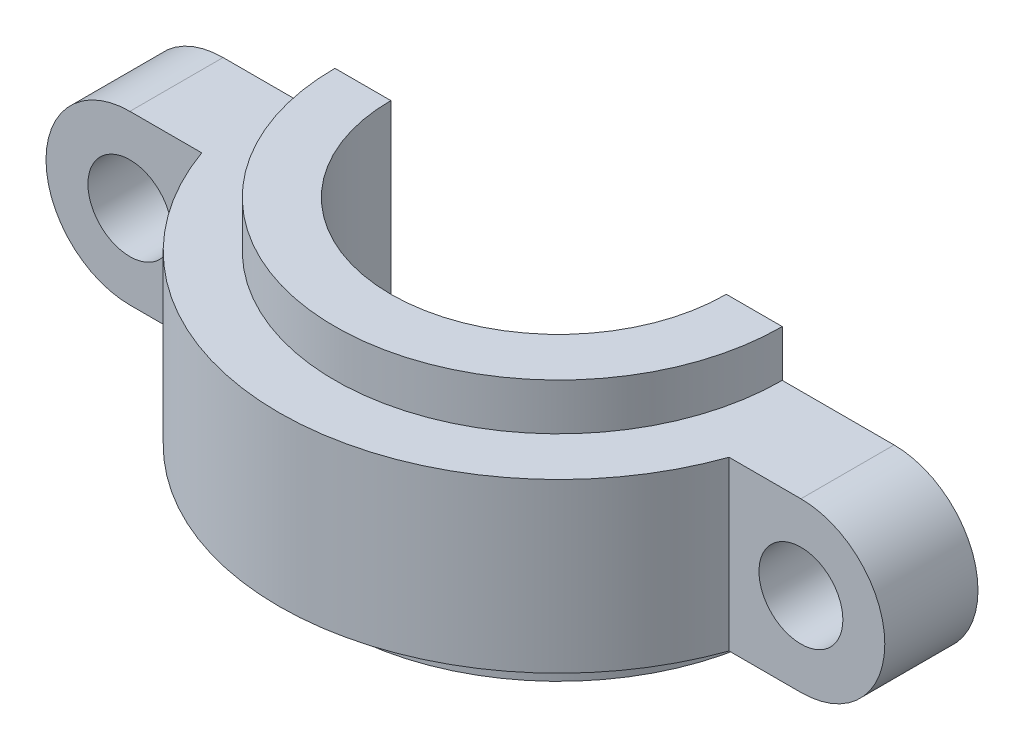
from build123d import *

# Parameters (mm, degrees)
SKETCH_1_R          = 4.5
EXTRUDE_1_DEPTH     = 10
EXTRUDE_2_DEPTH     = 9
EXTRUDE_3_DEPTH     = 14
CUT_EXTRUDE_1_DEPTH = 29


with BuildPart() as part:
    # 草圖1 → 填料-伸長1 (new body)
    with BuildSketch(Plane.XY):
        with BuildLine():
            Line((-36, 9), (36, 9))
            ThreePointArc((36, 9), (45, 0), (36, -9))
            Line((36, -9), (-36, -9))
            ThreePointArc((-36, -9), (-45, 0), (-36, 9))
        make_face()
        with Locations((36, 0)):
            Circle(SKETCH_1_R, mode=Mode.SUBTRACT)
        with Locations((-36, 0)):
            Circle(SKETCH_1_R, mode=Mode.SUBTRACT)
    extrude(amount=EXTRUDE_1_DEPTH)

    # 草圖3 → 填料-伸長2 (add, symmetric)
    with BuildSketch(Plane(origin=(0, 0, 0), x_dir=(1, 0, 0), z_dir=(0, 1, 0))):
        with BuildLine():
            Line((-30, 0), (30, 0))
            ThreePointArc((30, 0), (0, -30), (-30, 0))
        make_face()
    extrude(amount=EXTRUDE_2_DEPTH, both=True)

    # 草圖4 → 填料-伸長3 (add, symmetric)
    with BuildSketch(Plane(origin=(0, 0, 0), x_dir=(1, 0, 0), z_dir=(0, 1, 0))):
        with BuildLine():
            Line((-24, 0), (24, 0))
            ThreePointArc((24, 0), (0, -24), (-24, 0))
        make_face()
    extrude(amount=EXTRUDE_3_DEPTH, both=True)

    # 草圖5 → 除料-伸長1 (cut, through all)
    with BuildSketch(Plane(origin=(0, 14, 0), x_dir=(1, 0, 0), z_dir=(0, 1, 0))):
        with BuildLine():
            Line((-18, 0), (18, 0))
            ThreePointArc((18, 0), (0, -18), (-18, 0))
        make_face()
    extrude(amount=-CUT_EXTRUDE_1_DEPTH, mode=Mode.SUBTRACT)


solid = part.part
